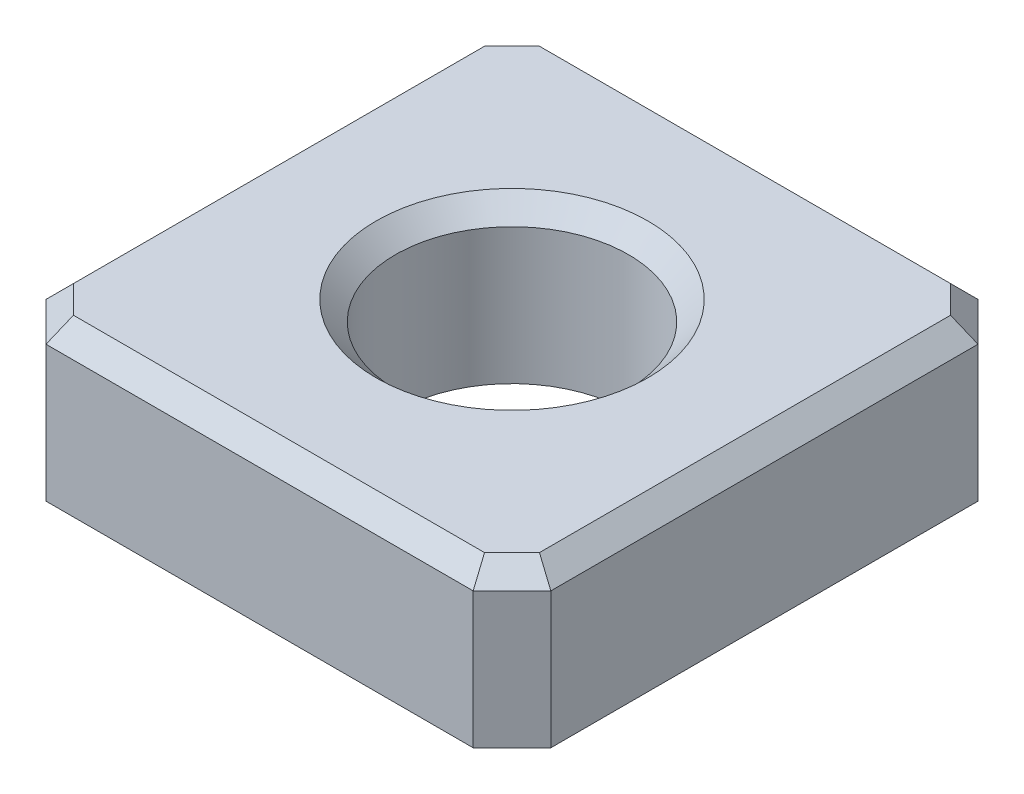
from build123d import *

# Parameters (mm, degrees)
SKETCH1_W           = 13
SKETCH1_H           = 13
SKETCH1_R           = 3
BOSS_EXTRUDE1_DEPTH = 4
CHAMFER1_SIZE       = 1
CHAMFER3_SIZE       = 0.5


with BuildPart() as part:
    # Sketch1 → Boss-Extrude1 (new body)
    with BuildSketch(Plane(origin=(0, 0, 0), x_dir=(1, 0, 0), z_dir=(0, 1, 0))):
        Rectangle(SKETCH1_W, SKETCH1_H)
        Circle(SKETCH1_R, mode=Mode.SUBTRACT)
    extrude(amount=BOSS_EXTRUDE1_DEPTH)

    # Chamfer1
    chamfer1_edges = [part.edges().sort_by_distance(p)[0] for p in [
        (6.5, 2, 6.5),
        (-6.5, 2, 6.5),
        (-6.5, 2, -6.5),
        (6.5, 2, -6.5),
    ]]
    chamfer(chamfer1_edges, length=CHAMFER1_SIZE)

    # Chamfer3
    chamfer3_edges = [part.edges().sort_by_distance(p)[0] for p in [
        (-3, 4, 0),
        (-6.5, 4, 0),
        (0, 4, -6.5),
        (6.5, 4, 0),
        (0, 4, 6.5),
        (6, 4, 6),
        (6, 4, -6),
        (-6, 4, 6),
        (-6, 4, -6),
    ]]
    chamfer(chamfer3_edges, length=CHAMFER3_SIZE)


solid = part.part
